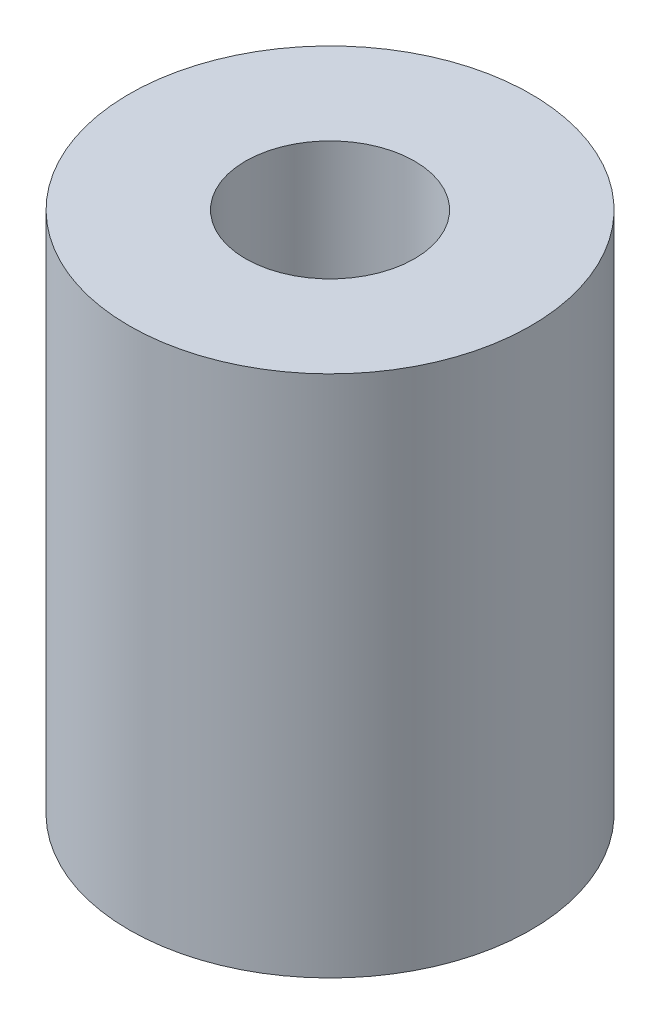
from build123d import *

# Parameters (mm, degrees)
SKETCH1_R           = 9.5
SKETCH1_R_2         = 4
BOSS_EXTRUDE1_DEPTH = 24.75


with BuildPart() as part:
    # Sketch1 → Boss-Extrude1 (new body)
    with BuildSketch(Plane(origin=(0, 0, 0), x_dir=(1, 0, 0), z_dir=(0, 1, 0))):
        Circle(SKETCH1_R)
        Circle(SKETCH1_R_2, mode=Mode.SUBTRACT)
    extrude(amount=BOSS_EXTRUDE1_DEPTH)


solid = part.part
